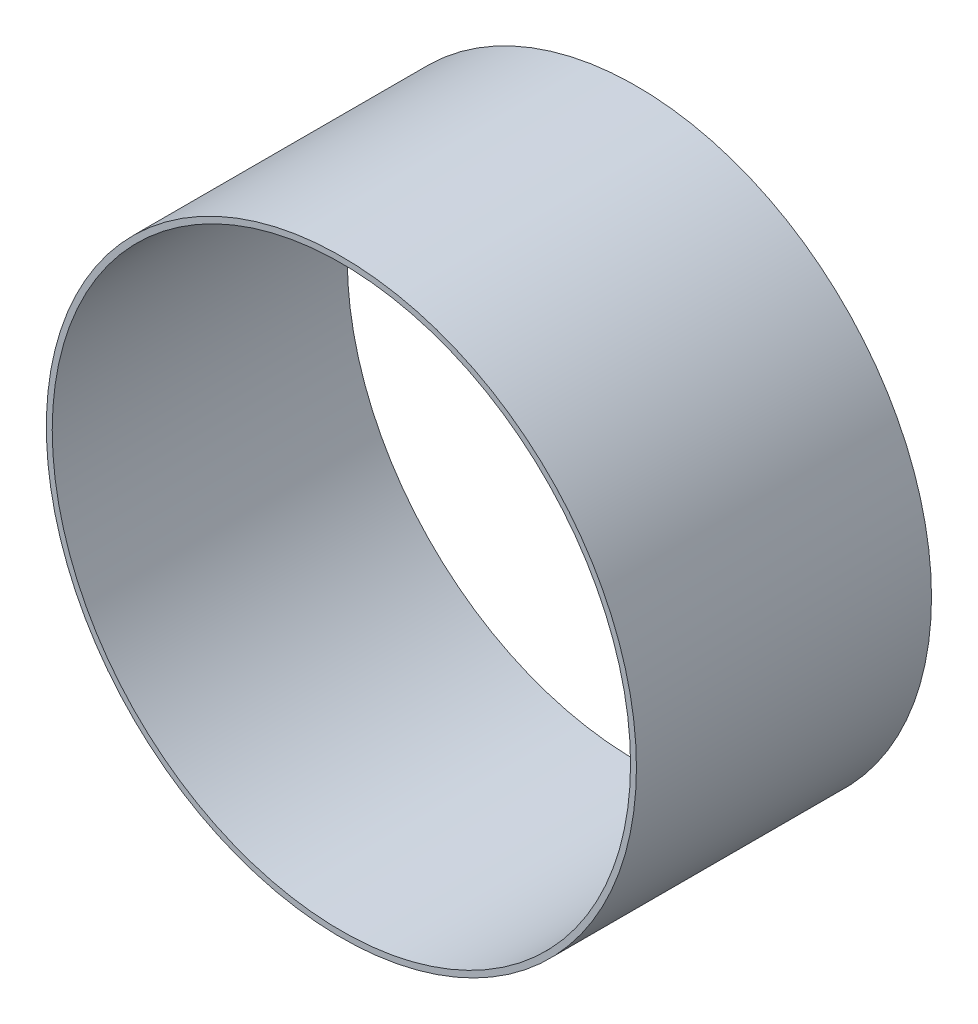
from build123d import *

# Parameters (mm, degrees)
SKETCH_1_R      = 100
SKETCH_1_R_2    = 98
EXTRUDE_1_DEPTH = 100


with BuildPart() as part:
    # 草图1 → 凸台-拉伸1 (new body)
    with BuildSketch(Plane.XY):
        Circle(SKETCH_1_R)
        Circle(SKETCH_1_R_2, mode=Mode.SUBTRACT)
    extrude(amount=EXTRUDE_1_DEPTH)


solid = part.part
